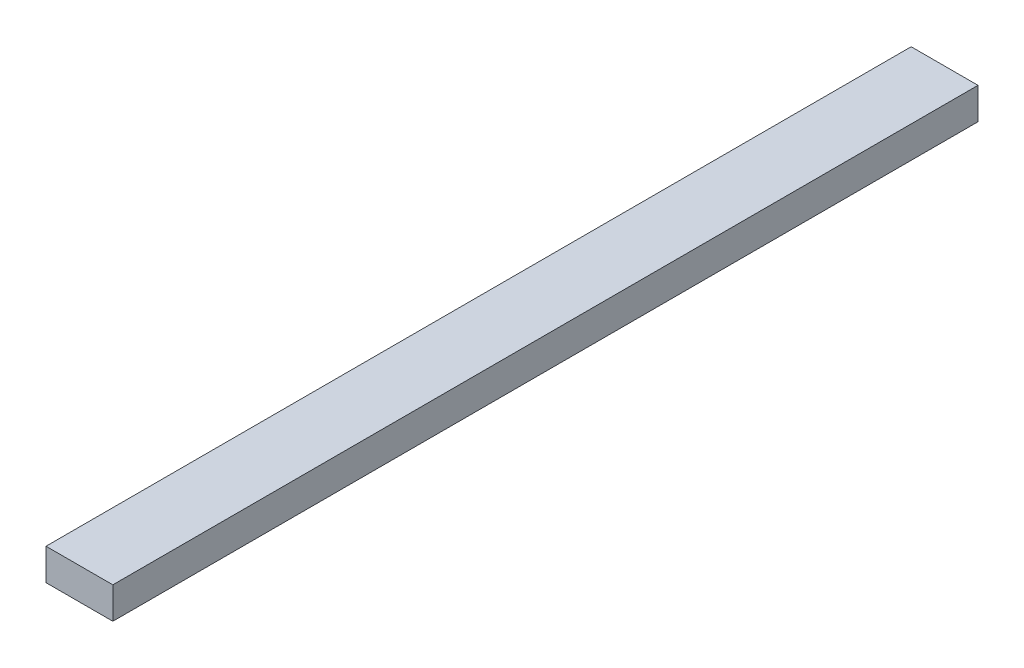
from build123d import *

# Parameters (mm, degrees)
SKETCH1_W           = 6.35
SKETCH1_H           = 3
BOSS_EXTRUDE1_DEPTH = 82.2


with BuildPart() as part:
    # Sketch1 → Boss-Extrude1 (new body)
    with BuildSketch(Plane.XY):
        Rectangle(SKETCH1_W, SKETCH1_H)
    extrude(amount=BOSS_EXTRUDE1_DEPTH)


solid = part.part
